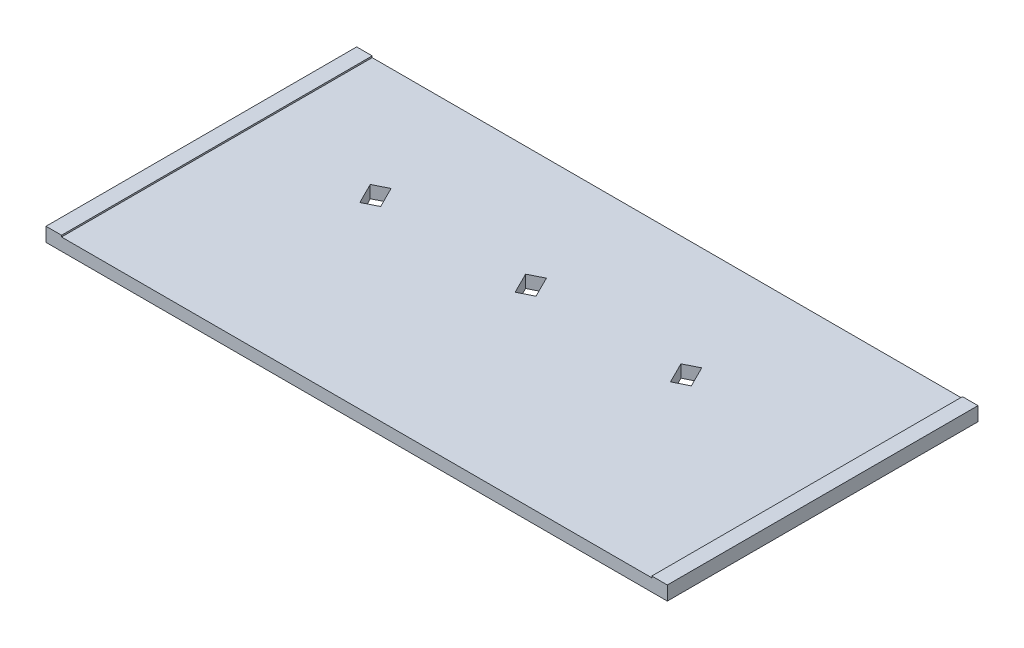
from build123d import *

# Parameters (mm, degrees)
SKETCH1_W           = 101.6
SKETCH1_H           = 50.8
BOSS_EXTRUDE1_DEPTH = 2.032
CUT_EXTRUDE1_DEPTH  = 3.032
LPATTERN1_COUNT     = 2
LPATTERN1_PITCH     = 25.4
LPATTERN1_COL_COUNT = 2
LPATTERN1_COL_PITCH = 25.4
SKETCH4_W           = 2.54
SKETCH4_H           = 50.8
BOSS_EXTRUDE2_DEPTH = 0.254


with BuildPart() as part:
    # Sketch1 → Boss-Extrude1 (new body)
    with BuildSketch(Plane(origin=(0, 0, 0), x_dir=(1, 0, 0), z_dir=(0, 1, 0))):
        Rectangle(SKETCH1_W, SKETCH1_H)
    extrude(amount=BOSS_EXTRUDE1_DEPTH)

    # Sketch2 → Cut-Extrude1 (cut, through all)
    with BuildSketch(Plane(origin=(0, 2.032, 0), x_dir=(1, 0, 0), z_dir=(0, 1, 0))):
        Polygon((-5.061841618, 7.282181714), (-2.790094674, 8.418300469), (-1.085916542, 5.010680054), (-3.357663485, 3.874561299), align=None)
    cut_extrude1 = extrude(amount=-CUT_EXTRUDE1_DEPTH, mode=Mode.SUBTRACT)

    # LPattern1: Cut-Extrude1 ×2
    with Locations(*[(-i * LPATTERN1_PITCH, 0, 0) for i in range(1, LPATTERN1_COUNT)]):
        add(cut_extrude1, mode=Mode.SUBTRACT)

    # LPattern1 col: Cut-Extrude1 ×2
    with Locations(*[(i * LPATTERN1_COL_PITCH, 0, 0) for i in range(1, LPATTERN1_COL_COUNT)]):
        add(cut_extrude1, mode=Mode.SUBTRACT)

    # Sketch4 → Boss-Extrude2 (add)
    with BuildSketch(Plane(origin=(0, 2.032, 0), x_dir=(1, 0, 0), z_dir=(0, 1, 0))):
        with Locations((-49.53, 0)):
            Rectangle(SKETCH4_W, SKETCH4_H)
        with Locations((49.53, 0)):
            Rectangle(SKETCH4_W, SKETCH4_H)
    extrude(amount=BOSS_EXTRUDE2_DEPTH)


solid = part.part
